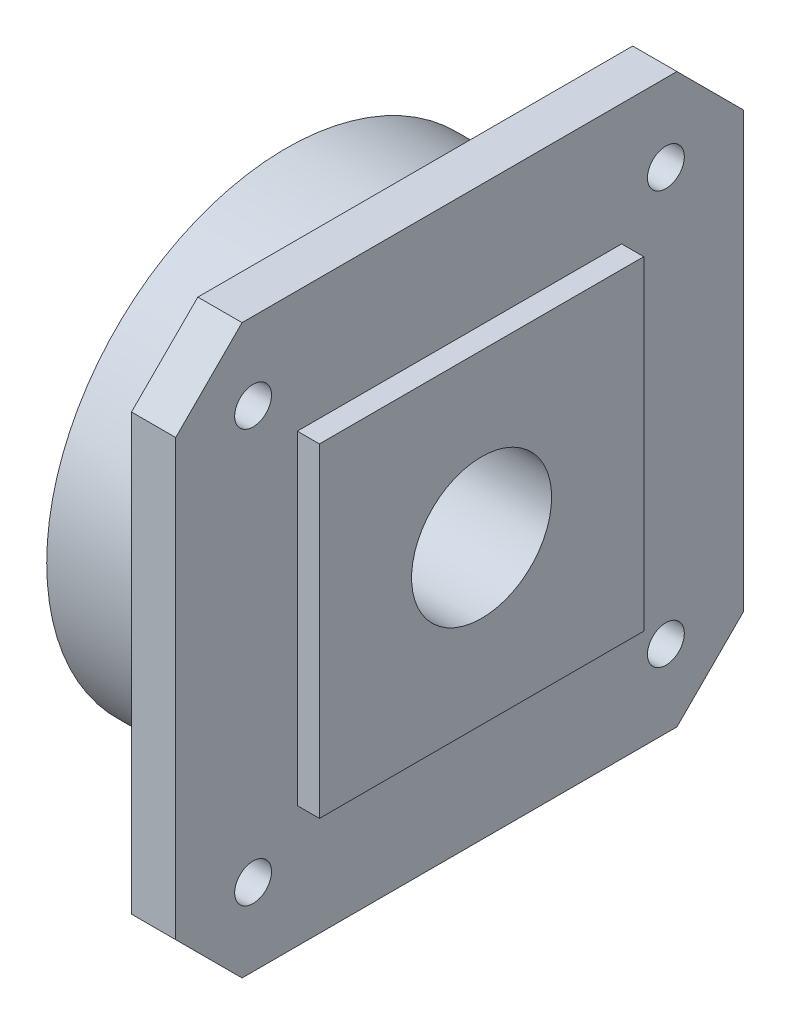
from build123d import *

# Parameters (mm, degrees)
EXTRUDE1_DEPTH            = 6
SKETCH2_W                 = 44
SKETCH2_H                 = 44
EXTRUDE2_DEPTH            = 3
SKETCH4_R                 = 32.5
EXTRUDE3_DEPTH            = 17.5
SKETCH3_R                 = 9.5
EXTRUDE4_DEPTH            = 27.5
SKETCH16_R                = 21
EXTRUDE7_DEPTH            = 12
SKETCH19_R                = 2.5
EXTRUDE8_DEPTH            = 24.5
LPATTERN1_COUNT           = 2
LPATTERN1_PITCH           = 56
LPATTERN2_COUNT           = 2
LPATTERN2_PITCH           = 56
LPATTERN2_COPY_1_SKETCH_R = 2.5
LPATTERN2_COPY_1_DEPTH    = 24.5


with BuildPart() as part:
    # Sketch1 → Extrude1 (new body)
    with BuildSketch(Plane(origin=(0, 0, 0), x_dir=(0, 0, -1), z_dir=(1, 0, 0))):
        Polygon((0, 68), (9, 77), (68, 77), (77, 68), (77, 9), (68, 0), (9, 0), (0, 9), align=None)
    extrude(amount=EXTRUDE1_DEPTH)

    # Sketch2 → Extrude2 (add)
    with BuildSketch(Plane(origin=(6, 0, 0), x_dir=(0, 0, -1), z_dir=(1, 0, 0))):
        with Locations((38.5, 38.5)):
            Rectangle(SKETCH2_W, SKETCH2_H)
    extrude(amount=EXTRUDE2_DEPTH)

    # Sketch4 → Extrude3 (add)
    with BuildSketch(Plane.ZY):
        with Locations((-38.5, 38.5)):
            Circle(SKETCH4_R)
    extrude(amount=EXTRUDE3_DEPTH)

    # Sketch3 → Extrude4 (cut, through all)
    with BuildSketch(Plane(origin=(9, 0, 0), x_dir=(0, 0, -1), z_dir=(1, 0, 0))):
        with Locations((38.5, 38.5)):
            Circle(SKETCH3_R)
    extrude(amount=-EXTRUDE4_DEPTH, mode=Mode.SUBTRACT)

    # Sketch16 → Extrude7 (cut)
    with BuildSketch(Plane.ZY.offset(17.5)):
        with Locations((-38.5, 38.5)):
            Circle(SKETCH16_R)
    extrude(amount=-EXTRUDE7_DEPTH, mode=Mode.SUBTRACT)

    # Sketch18 → Revolve2 (revolve)
    with BuildSketch(Plane.XZ.offset(-38.5)):
        Polygon((-5.5, -56.5), (-5.5, -59.5), (-17.5, -59.5), align=None)
    revolve(axis=Axis((9, 38.5, -38.5), (-1, 0, 0)))

    # Sketch19 → Extrude8 (cut, through all)
    with BuildSketch(Plane(origin=(6, 0, 0), x_dir=(0, 0, -1), z_dir=(1, 0, 0))):
        with Locations((10.5, 66.5)):
            Circle(SKETCH19_R)
    extrude8 = extrude(amount=-EXTRUDE8_DEPTH, mode=Mode.SUBTRACT)

    # LPattern1: Extrude8 ×2
    with Locations(*[(0, 0, -i * LPATTERN1_PITCH) for i in range(1, LPATTERN1_COUNT)]):
        add(extrude8, mode=Mode.SUBTRACT)

    # LPattern2: Extrude8 ×2
    with Locations(*[(0, -i * LPATTERN2_PITCH, 0) for i in range(1, LPATTERN2_COUNT)]):
        add(extrude8, mode=Mode.SUBTRACT)

    # LPattern2 copy 1 sketch → LPattern2 copy 1 (cut, through all)
    with BuildSketch(Plane(origin=(6, -56, -56), x_dir=(0, 0, -1), z_dir=(1, 0, 0))):
        with Locations((10.5, 66.5)):
            Circle(LPATTERN2_COPY_1_SKETCH_R)
    extrude(amount=-LPATTERN2_COPY_1_DEPTH, mode=Mode.SUBTRACT)


solid = part.part
